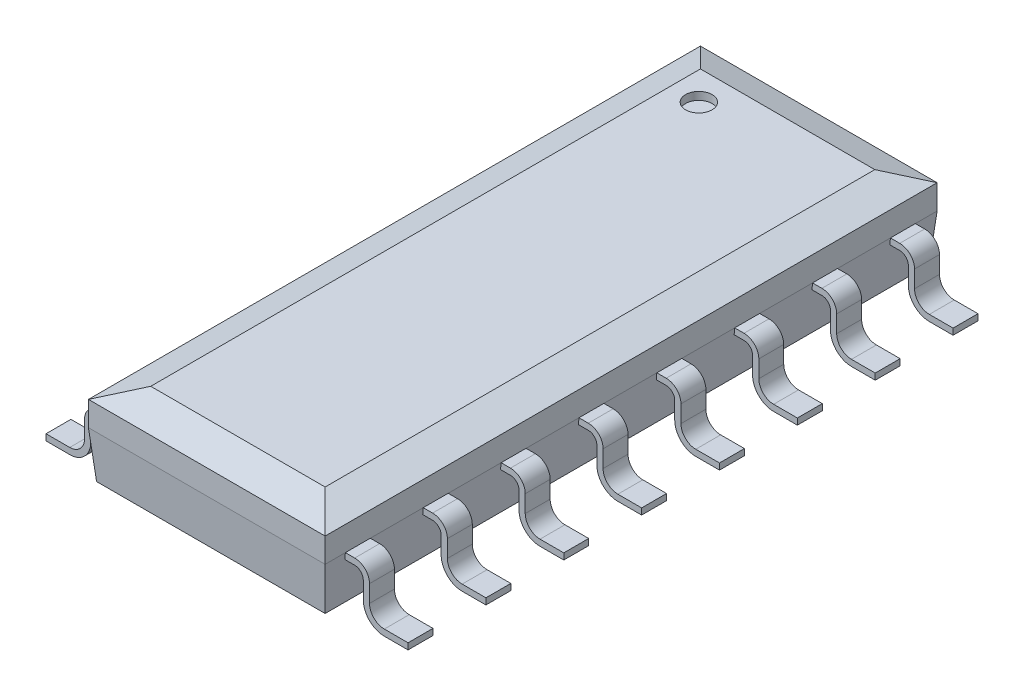
from build123d import *
from OCP.BRepFilletAPI import BRepFilletAPI_MakeChamfer

# Parameters (mm, degrees)
SKETCH1_W                = 9.9822
SKETCH1_H                = 1.3462
BASE_EXTRUDE_DEPTH       = 3.8608
CHAMFER1_SIZE            = 0.508
CHAMFER1_SIZE2           = 0.184896879
CHAMFER2_SIZE            = 0.762
CHAMFER2_SIZE2           = 0.066666362
SKETCH2_R                = 0.2159
CUT_EXTRUDE1_DEPTH       = 0.127
BOSS_EXTRUDE_THIN1_DEPTH = 0.2032
LPATTERN1_COUNT          = 8
LPATTERN1_PITCH          = 1.27
MIRROR1_COPY_1_DEPTH     = 0.2032
MIRROR1_COPY_2_DEPTH     = 0.2032
MIRROR1_COPY_3_DEPTH     = 0.2032
MIRROR1_COPY_4_DEPTH     = 0.2032
MIRROR1_COPY_5_DEPTH     = 0.2032
MIRROR1_COPY_6_DEPTH     = 0.2032
MIRROR1_COPY_7_DEPTH     = 0.2032


with BuildPart() as part:
    # Sketch1 → Base-Extrude (new body)
    with BuildSketch(Plane(origin=(0.762, 0, 0), x_dir=(0, 0, -1), z_dir=(1, 0, 0))):
        with Locations((-4.4323, 0.7747)):
            Rectangle(SKETCH1_W, SKETCH1_H)
    extrude(amount=BASE_EXTRUDE_DEPTH)

    # Chamfer1
    chamfer1_edges = [part.edges().sort_by_distance(p)[0] for p in [
        (0.762, 1.4478, 4.4323),
        (4.6228, 1.4478, 4.4323),
        (2.6924, 1.4478, 9.4234),
        (2.6924, 1.4478, -0.5588),
    ]]
    chamfer1_side = [part.faces().sort_by_distance(p)[0] for p in [
        (2.6924, 1.4478, 4.4323),
    ]]
    chamfer(chamfer1_edges, length=CHAMFER1_SIZE, length2=CHAMFER1_SIZE2, reference=chamfer1_side[0])

    # Chamfer2: one chamfer whose edges measure the first distance from different faces: ONE call of the kernel's chamfer builder (chamfer() names one face for all edges)
    chamfer2_edges_1 = [part.edges().sort_by_distance(p)[0] for p in [
        (4.6228, 0.1016, 4.4323),
    ]]
    chamfer2_side_1 = [part.faces().sort_by_distance(p)[0] for p in [
        (4.6228, 0.68225156, 4.4323),
    ]]
    chamfer2_edges_2 = [part.edges().sort_by_distance(p)[0] for p in [
        (0.762, 0.1016, 4.4323),
    ]]
    chamfer2_side_2 = [part.faces().sort_by_distance(p)[0] for p in [
        (0.762, 0.68225156, 4.4323),
    ]]
    chamfer2_edges_3 = [part.edges().sort_by_distance(p)[0] for p in [
        (2.6924, 0.1016, -0.5588),
    ]]
    chamfer2_side_3 = [part.faces().sort_by_distance(p)[0] for p in [
        (2.6924, 0.68225156, -0.5588),
    ]]
    chamfer2_edges_4 = [part.edges().sort_by_distance(p)[0] for p in [
        (2.6924, 0.1016, 9.4234),
    ]]
    chamfer2_side_4 = [part.faces().sort_by_distance(p)[0] for p in [
        (2.6924, 0.68225156, 9.4234),
    ]]
    chamfer2 = BRepFilletAPI_MakeChamfer(part.part.solid().wrapped)
    for e in chamfer2_edges_1:
        chamfer2.Add(CHAMFER2_SIZE, CHAMFER2_SIZE2, e.wrapped, chamfer2_side_1[0].wrapped)  # the first distance lies on this face
    for e in chamfer2_edges_2:
        chamfer2.Add(CHAMFER2_SIZE, CHAMFER2_SIZE2, e.wrapped, chamfer2_side_2[0].wrapped)  # the first distance lies on this face
    for e in chamfer2_edges_3:
        chamfer2.Add(CHAMFER2_SIZE, CHAMFER2_SIZE2, e.wrapped, chamfer2_side_3[0].wrapped)  # the first distance lies on this face
    for e in chamfer2_edges_4:
        chamfer2.Add(CHAMFER2_SIZE, CHAMFER2_SIZE2, e.wrapped, chamfer2_side_4[0].wrapped)  # the first distance lies on this face
    add(Compound.cast(chamfer2.Shape()), mode=Mode.REPLACE)

    # Sketch2 → Cut-Extrude1 (cut)
    with BuildSketch(Plane(origin=(0, 1.4478, 0), x_dir=(-1, 0, 0), z_dir=(0, 1, 0))):
        with Locations(Location((-1.7272, 0.4318, 0), (0, 0, 90))):
            Circle(SKETCH2_R)
    extrude(amount=-CUT_EXTRUDE1_DEPTH, mode=Mode.SUBTRACT)

    # Sketch3 → Boss-Extrude-Thin1 (add, symmetric)
    with BuildSketch(Plane.XY):
        with BuildLine():
            Line((1.452090171, 0.8636), (0.6096, 0.8636))
            ThreePointArc((0.6096, 0.8636), (0.438975134, 0.792924866), (0.3683, 0.6223))
            Line((0.3683, 0.6223), (0.3683, 0.3429))
            ThreePointArc((0.3683, 0.3429), (0.297624866, 0.172275134), (0.127, 0.1016))
            Line((0.127, 0.1016), (-0.260272549, 0.1016))
            Line((-0.260272549, 0.1016), (-0.260272549, 0))
            Line((-0.260272549, 0), (0.127, 0))
            ThreePointArc((0.127, 0), (0.369466915, 0.100433085), (0.4699, 0.3429))
            Line((0.4699, 0.3429), (0.4699, 0.6223))
            ThreePointArc((0.4699, 0.6223), (0.510817183, 0.721082817), (0.6096, 0.762))
            Line((0.6096, 0.762), (1.452090171, 0.762))
            Line((1.452090171, 0.762), (1.452090171, 0.8636))
        make_face()
    boss_extrude_thin1 = extrude(amount=BOSS_EXTRUDE_THIN1_DEPTH, both=True)

    # LPattern1: Boss-Extrude-Thin1 ×8
    with Locations(*[(0, 0, i * LPATTERN1_PITCH) for i in range(1, LPATTERN1_COUNT)]):
        add(boss_extrude_thin1)

    # Mirror1: Boss-Extrude-Thin1 across plane
    add(boss_extrude_thin1.mirror(Plane.ZY.offset(-2.6924)))

    # Mirror1 copy 1 sketch → Mirror1 copy 1 (add, symmetric)
    with BuildSketch(Plane(origin=(5.3848, 0, 1.27), x_dir=(-1, 0, 0), z_dir=(0, 0, 1))):
        with BuildLine():
            Line((1.452090171, -0.8636), (0.6096, -0.8636))
            ThreePointArc((0.6096, -0.8636), (0.438975134, -0.792924866), (0.3683, -0.6223))
            Line((0.3683, -0.6223), (0.3683, -0.3429))
            ThreePointArc((0.3683, -0.3429), (0.297624866, -0.172275134), (0.127, -0.1016))
            Line((0.127, -0.1016), (-0.260272549, -0.1016))
            Line((-0.260272549, -0.1016), (-0.260272549, 0))
            Line((-0.260272549, 0), (0.127, 0))
            ThreePointArc((0.127, 0), (0.369466915, -0.100433085), (0.4699, -0.3429))
            Line((0.4699, -0.3429), (0.4699, -0.6223))
            ThreePointArc((0.4699, -0.6223), (0.510817183, -0.721082817), (0.6096, -0.762))
            Line((0.6096, -0.762), (1.452090171, -0.762))
            Line((1.452090171, -0.762), (1.452090171, -0.8636))
        make_face()
    extrude(amount=MIRROR1_COPY_1_DEPTH, both=True)

    # Mirror1 copy 2 sketch → Mirror1 copy 2 (add, symmetric)
    with BuildSketch(Plane(origin=(5.3848, 0, 2.54), x_dir=(-1, 0, 0), z_dir=(0, 0, 1))):
        with BuildLine():
            Line((1.452090171, -0.8636), (0.6096, -0.8636))
            ThreePointArc((0.6096, -0.8636), (0.438975134, -0.792924866), (0.3683, -0.6223))
            Line((0.3683, -0.6223), (0.3683, -0.3429))
            ThreePointArc((0.3683, -0.3429), (0.297624866, -0.172275134), (0.127, -0.1016))
            Line((0.127, -0.1016), (-0.260272549, -0.1016))
            Line((-0.260272549, -0.1016), (-0.260272549, 0))
            Line((-0.260272549, 0), (0.127, 0))
            ThreePointArc((0.127, 0), (0.369466915, -0.100433085), (0.4699, -0.3429))
            Line((0.4699, -0.3429), (0.4699, -0.6223))
            ThreePointArc((0.4699, -0.6223), (0.510817183, -0.721082817), (0.6096, -0.762))
            Line((0.6096, -0.762), (1.452090171, -0.762))
            Line((1.452090171, -0.762), (1.452090171, -0.8636))
        make_face()
    extrude(amount=MIRROR1_COPY_2_DEPTH, both=True)

    # Mirror1 copy 3 sketch → Mirror1 copy 3 (add, symmetric)
    with BuildSketch(Plane(origin=(5.3848, 0, 3.81), x_dir=(-1, 0, 0), z_dir=(0, 0, 1))):
        with BuildLine():
            Line((1.452090171, -0.8636), (0.6096, -0.8636))
            ThreePointArc((0.6096, -0.8636), (0.438975134, -0.792924866), (0.3683, -0.6223))
            Line((0.3683, -0.6223), (0.3683, -0.3429))
            ThreePointArc((0.3683, -0.3429), (0.297624866, -0.172275134), (0.127, -0.1016))
            Line((0.127, -0.1016), (-0.260272549, -0.1016))
            Line((-0.260272549, -0.1016), (-0.260272549, 0))
            Line((-0.260272549, 0), (0.127, 0))
            ThreePointArc((0.127, 0), (0.369466915, -0.100433085), (0.4699, -0.3429))
            Line((0.4699, -0.3429), (0.4699, -0.6223))
            ThreePointArc((0.4699, -0.6223), (0.510817183, -0.721082817), (0.6096, -0.762))
            Line((0.6096, -0.762), (1.452090171, -0.762))
            Line((1.452090171, -0.762), (1.452090171, -0.8636))
        make_face()
    extrude(amount=MIRROR1_COPY_3_DEPTH, both=True)

    # Mirror1 copy 4 sketch → Mirror1 copy 4 (add, symmetric)
    with BuildSketch(Plane(origin=(5.3848, 0, 5.08), x_dir=(-1, 0, 0), z_dir=(0, 0, 1))):
        with BuildLine():
            Line((1.452090171, -0.8636), (0.6096, -0.8636))
            ThreePointArc((0.6096, -0.8636), (0.438975134, -0.792924866), (0.3683, -0.6223))
            Line((0.3683, -0.6223), (0.3683, -0.3429))
            ThreePointArc((0.3683, -0.3429), (0.297624866, -0.172275134), (0.127, -0.1016))
            Line((0.127, -0.1016), (-0.260272549, -0.1016))
            Line((-0.260272549, -0.1016), (-0.260272549, 0))
            Line((-0.260272549, 0), (0.127, 0))
            ThreePointArc((0.127, 0), (0.369466915, -0.100433085), (0.4699, -0.3429))
            Line((0.4699, -0.3429), (0.4699, -0.6223))
            ThreePointArc((0.4699, -0.6223), (0.510817183, -0.721082817), (0.6096, -0.762))
            Line((0.6096, -0.762), (1.452090171, -0.762))
            Line((1.452090171, -0.762), (1.452090171, -0.8636))
        make_face()
    extrude(amount=MIRROR1_COPY_4_DEPTH, both=True)

    # Mirror1 copy 5 sketch → Mirror1 copy 5 (add, symmetric)
    with BuildSketch(Plane(origin=(5.3848, 0, 6.35), x_dir=(-1, 0, 0), z_dir=(0, 0, 1))):
        with BuildLine():
            Line((1.452090171, -0.8636), (0.6096, -0.8636))
            ThreePointArc((0.6096, -0.8636), (0.438975134, -0.792924866), (0.3683, -0.6223))
            Line((0.3683, -0.6223), (0.3683, -0.3429))
            ThreePointArc((0.3683, -0.3429), (0.297624866, -0.172275134), (0.127, -0.1016))
            Line((0.127, -0.1016), (-0.260272549, -0.1016))
            Line((-0.260272549, -0.1016), (-0.260272549, 0))
            Line((-0.260272549, 0), (0.127, 0))
            ThreePointArc((0.127, 0), (0.369466915, -0.100433085), (0.4699, -0.3429))
            Line((0.4699, -0.3429), (0.4699, -0.6223))
            ThreePointArc((0.4699, -0.6223), (0.510817183, -0.721082817), (0.6096, -0.762))
            Line((0.6096, -0.762), (1.452090171, -0.762))
            Line((1.452090171, -0.762), (1.452090171, -0.8636))
        make_face()
    extrude(amount=MIRROR1_COPY_5_DEPTH, both=True)

    # Mirror1 copy 6 sketch → Mirror1 copy 6 (add, symmetric)
    with BuildSketch(Plane(origin=(5.3848, 0, 7.62), x_dir=(-1, 0, 0), z_dir=(0, 0, 1))):
        with BuildLine():
            Line((1.452090171, -0.8636), (0.6096, -0.8636))
            ThreePointArc((0.6096, -0.8636), (0.438975134, -0.792924866), (0.3683, -0.6223))
            Line((0.3683, -0.6223), (0.3683, -0.3429))
            ThreePointArc((0.3683, -0.3429), (0.297624866, -0.172275134), (0.127, -0.1016))
            Line((0.127, -0.1016), (-0.260272549, -0.1016))
            Line((-0.260272549, -0.1016), (-0.260272549, 0))
            Line((-0.260272549, 0), (0.127, 0))
            ThreePointArc((0.127, 0), (0.369466915, -0.100433085), (0.4699, -0.3429))
            Line((0.4699, -0.3429), (0.4699, -0.6223))
            ThreePointArc((0.4699, -0.6223), (0.510817183, -0.721082817), (0.6096, -0.762))
            Line((0.6096, -0.762), (1.452090171, -0.762))
            Line((1.452090171, -0.762), (1.452090171, -0.8636))
        make_face()
    extrude(amount=MIRROR1_COPY_6_DEPTH, both=True)

    # Mirror1 copy 7 sketch → Mirror1 copy 7 (add, symmetric)
    with BuildSketch(Plane(origin=(5.3848, 0, 8.89), x_dir=(-1, 0, 0), z_dir=(0, 0, 1))):
        with BuildLine():
            Line((1.452090171, -0.8636), (0.6096, -0.8636))
            ThreePointArc((0.6096, -0.8636), (0.438975134, -0.792924866), (0.3683, -0.6223))
            Line((0.3683, -0.6223), (0.3683, -0.3429))
            ThreePointArc((0.3683, -0.3429), (0.297624866, -0.172275134), (0.127, -0.1016))
            Line((0.127, -0.1016), (-0.260272549, -0.1016))
            Line((-0.260272549, -0.1016), (-0.260272549, 0))
            Line((-0.260272549, 0), (0.127, 0))
            ThreePointArc((0.127, 0), (0.369466915, -0.100433085), (0.4699, -0.3429))
            Line((0.4699, -0.3429), (0.4699, -0.6223))
            ThreePointArc((0.4699, -0.6223), (0.510817183, -0.721082817), (0.6096, -0.762))
            Line((0.6096, -0.762), (1.452090171, -0.762))
            Line((1.452090171, -0.762), (1.452090171, -0.8636))
        make_face()
    extrude(amount=MIRROR1_COPY_7_DEPTH, both=True)


solid = part.part
